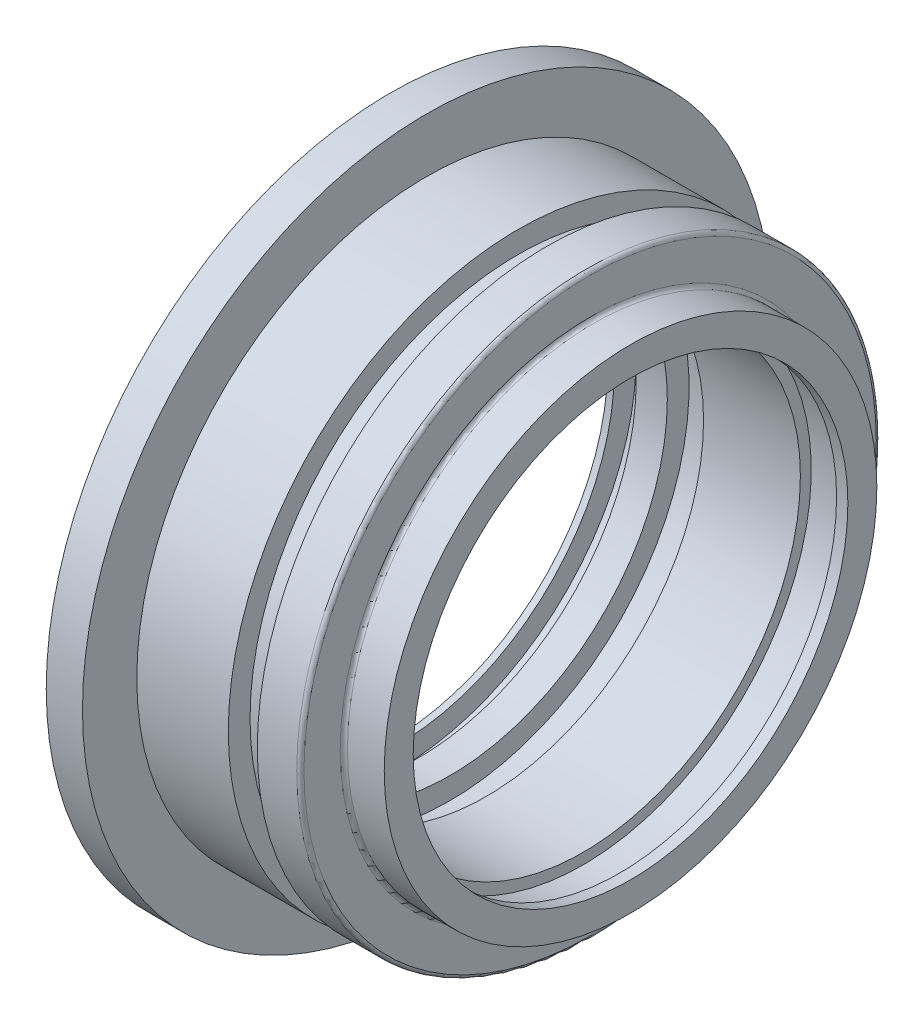
from build123d import *


with BuildPart() as part:
    # Sketch1 → Revolve1 (revolve)
    with BuildSketch(Plane.XY):
        with BuildLine():
            Line((-70.664700289, -47.5), (-65.664700289, -47.5))
            Line((-65.664700289, -47.5), (-65.664700289, -40))
            Line((-65.664700289, -40), (-53.033215522, -40))
            Line((-53.033215522, -40), (-53.033215522, -37))
            Line((-53.033215522, -37), (-49.033215522, -37))
            Line((-49.033215522, -37), (-49.033215522, -40))
            Line((-49.033215522, -40), (-43.588058898, -40))
            ThreePointArc((-43.588058898, -40), (-43.234505508, -39.853553391), (-43.088058898, -39.5))
            Line((-43.088058898, -39.5), (-43.088058898, -34.5))
            ThreePointArc((-43.088058898, -34.5), (-42.941612289, -34.146446609), (-42.588058898, -34))
            Line((-42.588058898, -34), (-37.50828788, -34))
            Line((-37.50828788, -34), (-37.50828788, -30))
            Line((-37.50828788, -30), (-39.064374409, -30))
            Line((-39.064374409, -30), (-39.064374409, -31.5))
            Line((-39.064374409, -31.5), (-44.064374409, -31.5))
            Line((-44.064374409, -31.5), (-44.064374409, -30))
            Line((-44.064374409, -30), (-57.429010066, -30))
            Line((-57.429010066, -30), (-57.429010066, -33))
            Line((-57.429010066, -33), (-62.429010066, -33))
            Line((-62.429010066, -33), (-62.429010066, -30))
            Line((-62.429010066, -30), (-66.725082253, -30))
            Line((-66.725082253, -30), (-66.725082253, -33))
            Line((-66.725082253, -33), (-69.725082253, -33))
            Line((-69.725082253, -33), (-69.725082253, -30))
            Line((-69.725082253, -30), (-70.664700289, -30))
            Line((-70.664700289, -30), (-70.664700289, -47.5))
        make_face()
    revolve(axis=Axis((-81.578167515, 0, 0), (1, 0, 0)))


solid = part.part
